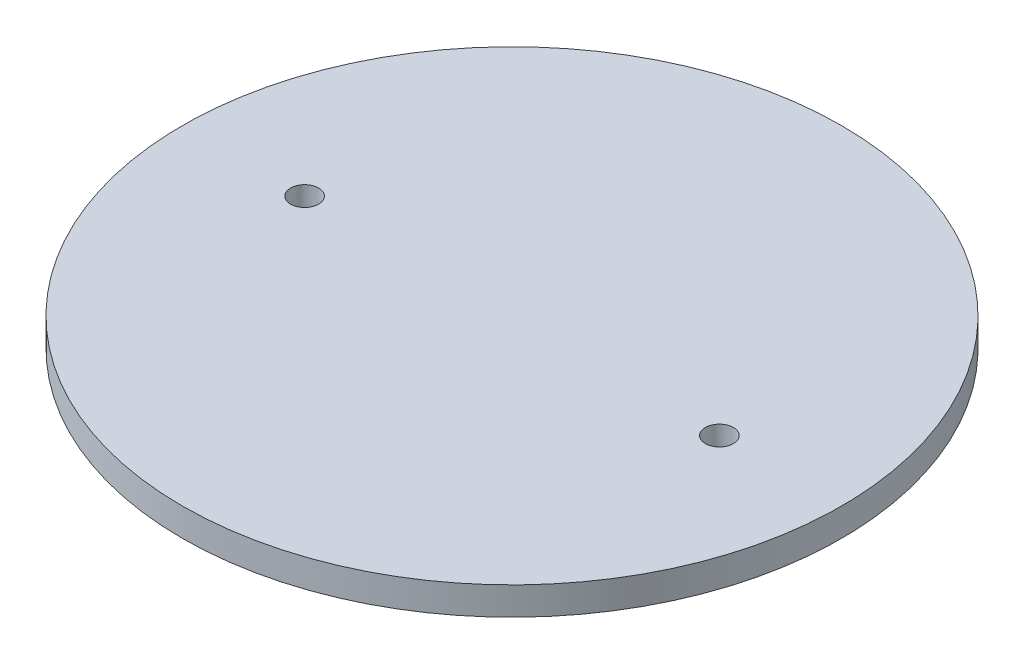
from build123d import *

# Parameters (mm, degrees)
SKETCH1_R           = 74.676
BOSS_EXTRUDE1_DEPTH = 6.35
SKETCH3_R           = 3.175
F_1_4_HOLES_DEPTH   = 6.35


with BuildPart() as part:
    # Sketch1 → Boss-Extrude1 (new body)
    with BuildSketch(Plane(origin=(0, 0, 0), x_dir=(1, 0, 0), z_dir=(0, 1, 0))):
        Circle(SKETCH1_R)
    extrude(amount=BOSS_EXTRUDE1_DEPTH)

    # Sketch3 → 1/4 Holes (cut)
    with BuildSketch(Plane(origin=(0, 6.35, 0), x_dir=(1, 0, 0), z_dir=(0, 1, 0))):
        with Locations((-46.99, 0)):
            Circle(SKETCH3_R)
        with Locations((46.99, 0)):
            Circle(SKETCH3_R)
    extrude(amount=-F_1_4_HOLES_DEPTH, mode=Mode.SUBTRACT)


solid = part.part
